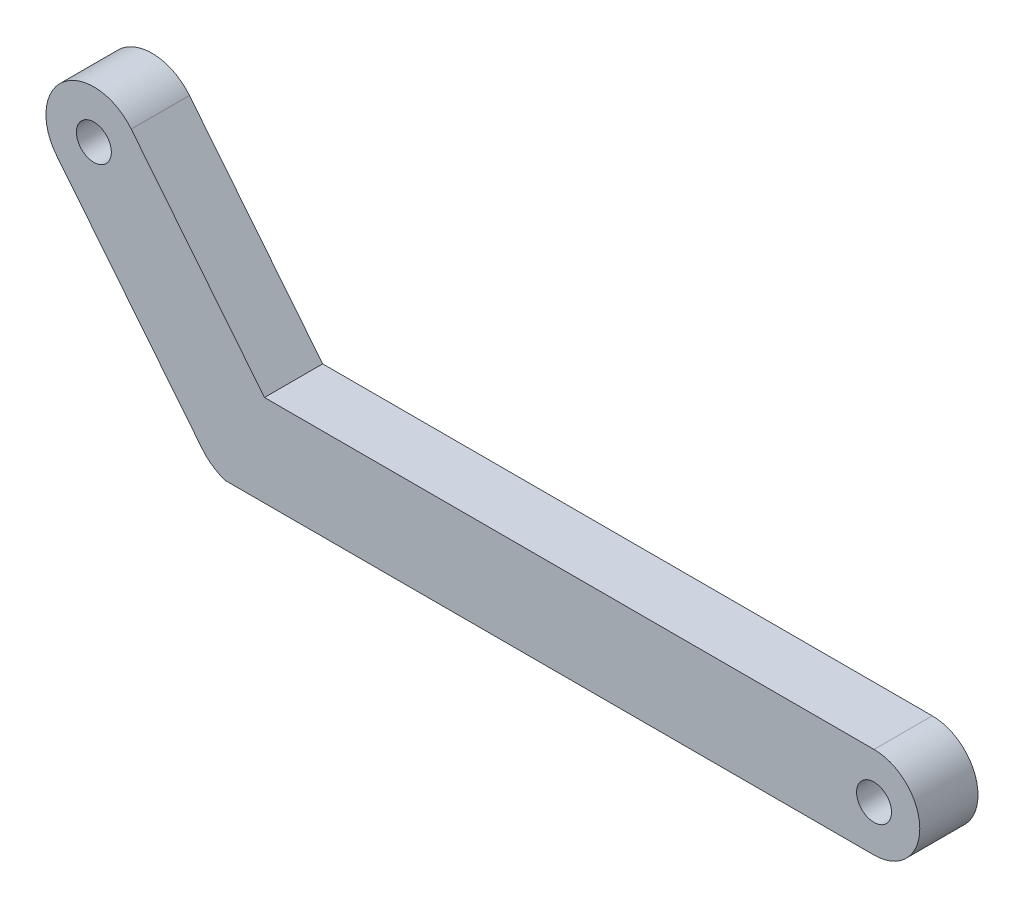
from build123d import *

# Parameters (mm, degrees)
SKETCH1_R           = 1.5
BOSS_EXTRUDE2_DEPTH = 5


with BuildPart() as part:
    # Sketch1 → Boss-Extrude2 (new body)
    with BuildSketch(Plane.XY):
        with BuildLine():
            ThreePointArc((1.550594596, 18.168790447), (-4.235995189, 18.799274261), (-4.866479002, 13.012684476))
            Line((-4.866479002, 13.012684476), (7.66064778, -2.578052986))
            ThreePointArc((7.66064778, -2.578052986), (8.549937722, -3.400317574), (9.640055191, -3.928142886))
            Line((9.640055191, -3.928142886), (65.342057797, -3.928142886))
            ThreePointArc((65.342057797, -3.928142886), (69.270200683, 0), (65.342057797, 3.928142886))
            Line((65.342057797, 3.928142886), (48.461164636, 3.928142886))
            Line((48.461164636, 3.928142886), (12.992926807, 3.928142886))
            Line((12.992926807, 3.928142886), (4.83629607, 14.07954397))
            Line((4.83629607, 14.07954397), (1.550594596, 18.168790447))
        make_face()
        with Locations((-1.657942203, 15.590737462)):
            Circle(SKETCH1_R, mode=Mode.SUBTRACT)
        with Locations((65.342057797, 0)):
            Circle(SKETCH1_R, mode=Mode.SUBTRACT)
    extrude(amount=BOSS_EXTRUDE2_DEPTH)


solid = part.part
